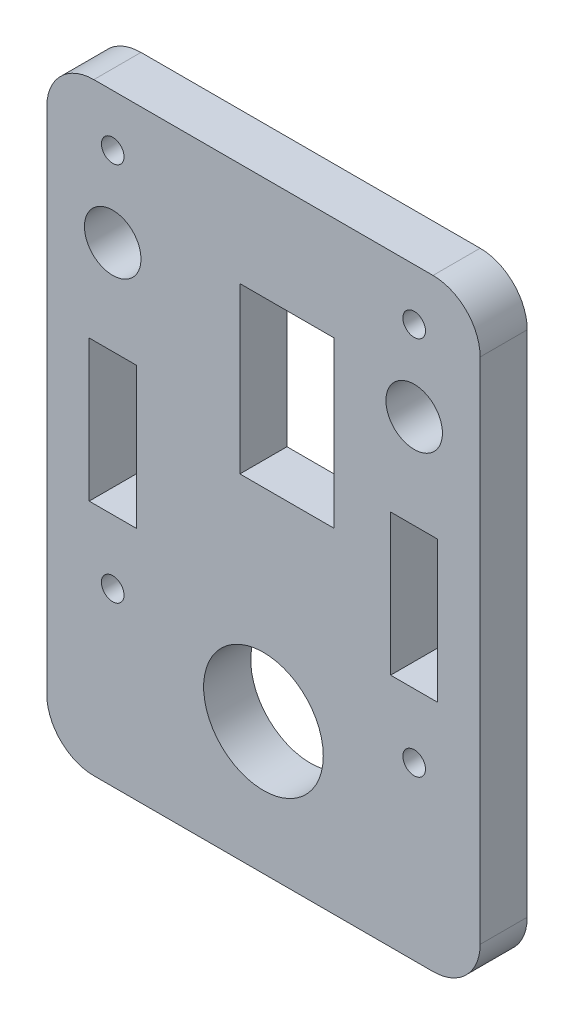
from build123d import *

# Parameters (mm, degrees)
SKETCH1_W           = 46
SKETCH1_H           = 64
SKETCH1_R           = 3
SKETCH1_R_2         = 1.2
SKETCH1_R_3         = 6.35
SKETCH1_W_2         = 5
SKETCH1_H_2         = 15
SKETCH1_W_3         = 10
SKETCH1_H_3         = 17.5
BOSS_EXTRUDE1_DEPTH = 5
FILLET1_R           = 5


with BuildPart() as part:
    # Sketch1 → Boss-Extrude1 (new body)
    with BuildSketch(Plane.XY):
        with Locations((0, 32)):
            Rectangle(SKETCH1_W, SKETCH1_H)
        with Locations((16, 50)):
            Circle(SKETCH1_R, mode=Mode.SUBTRACT)
        with Locations((16, 18.2)):
            Circle(SKETCH1_R_2, mode=Mode.SUBTRACT)
        with Locations((16, 58.5)):
            Circle(SKETCH1_R_2, mode=Mode.SUBTRACT)
        with Locations((-16, 58.5)):
            Circle(SKETCH1_R_2, mode=Mode.SUBTRACT)
        with Locations((-16, 18.2)):
            Circle(SKETCH1_R_2, mode=Mode.SUBTRACT)
        with Locations((-16, 50)):
            Circle(SKETCH1_R, mode=Mode.SUBTRACT)
        with Locations((0, 14)):
            Circle(SKETCH1_R_3, mode=Mode.SUBTRACT)
        with Locations((16, 32.5)):
            Rectangle(SKETCH1_W_2, SKETCH1_H_2, mode=Mode.SUBTRACT)
        with Locations((2.5, 44.25)):
            Rectangle(SKETCH1_W_3, SKETCH1_H_3, mode=Mode.SUBTRACT)
        with Locations((-16, 32.5)):
            Rectangle(SKETCH1_W_2, SKETCH1_H_2, mode=Mode.SUBTRACT)
    extrude(amount=BOSS_EXTRUDE1_DEPTH)

    # Fillet1
    fillet1_edges = [part.edges().sort_by_distance(p)[0] for p in [
        (23, 0, 2.5),
        (-23, 0, 2.5),
        (-23, 64, 2.5),
        (23, 64, 2.5),
    ]]
    fillet(fillet1_edges, radius=FILLET1_R)


solid = part.part
